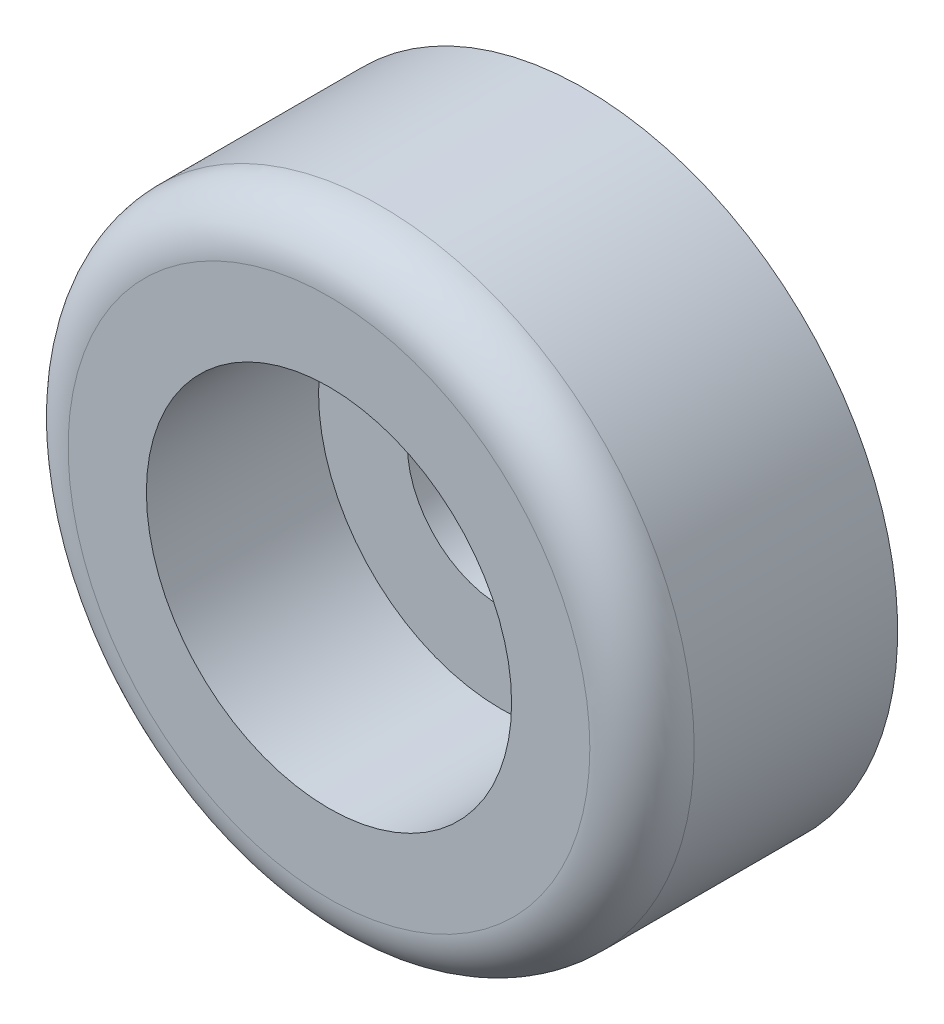
from build123d import *

# Parameters (mm, degrees)
REDONDEO1_R = 1


with BuildPart() as part:
    # Croquis1 → Revolución1 (revolve)
    with BuildSketch(Plane(origin=(0, 0, 0), x_dir=(0, 0, -1), z_dir=(1, 0, 0))):
        Polygon((0, 1.8), (0, 6), (-4.9, 6), (-4.9, 3.5), (-1.6, 3.5), (-1.6, 1.8), align=None)
    revolve(axis=Axis((0, 0, 0), (0, 0, 1)))

    # Redondeo1
    redondeo1_edges = [part.edges().sort_by_distance(p)[0] for p in [
        (0, -6, 4.9),
    ]]
    fillet(redondeo1_edges, radius=REDONDEO1_R)


solid = part.part
